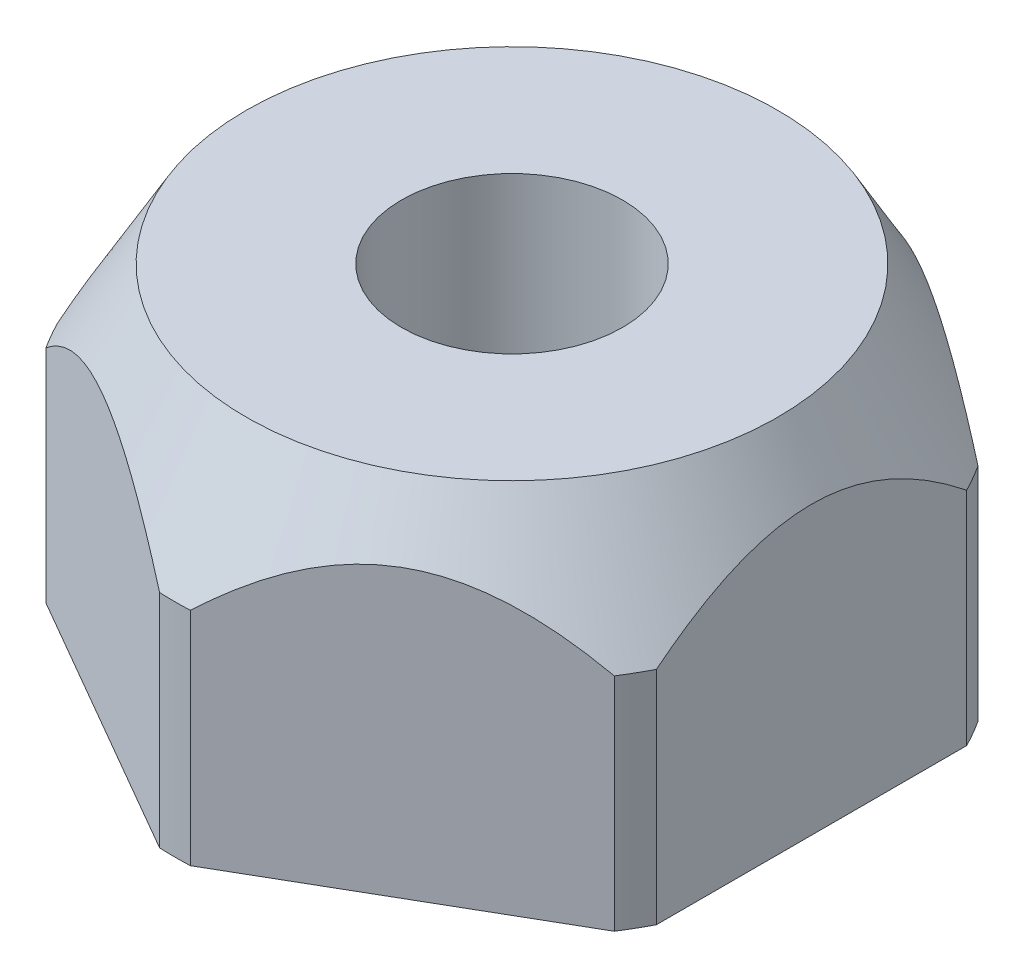
from build123d import *

# Parameters (mm, degrees)
SKETCH2_R      = 8.336997649
EXTRUDE1_DEPTH = 5.5212


with BuildPart() as part:
    # Sketch1 → Revolve1 (revolve)
    with BuildSketch(Plane.XY):
        Polygon((-1.4478, 0), (-4.4196, 0), (-4.4196, 2.897645717), (-3.482240498, 4.5212), (-1.4478, 4.5212), align=None)
    revolve(axis=Axis((0, 4.5212, 0), (0, -1, 0)))

    # Sketch2 → Extrude1 (cut, through all)
    with BuildSketch(Plane(origin=(0, 0, 0), x_dir=(1, 0, 0), z_dir=(0, 1, 0))):
        Circle(SKETCH2_R)
        Polygon((0, 4.531391323), (-3.9243, 2.265695661), (-3.9243, -2.265695661), (0, -4.531391323), (3.9243, -2.265695661), (3.9243, 2.265695661), align=None, mode=Mode.SUBTRACT)
    extrude(amount=EXTRUDE1_DEPTH, mode=Mode.SUBTRACT)


solid = part.part
